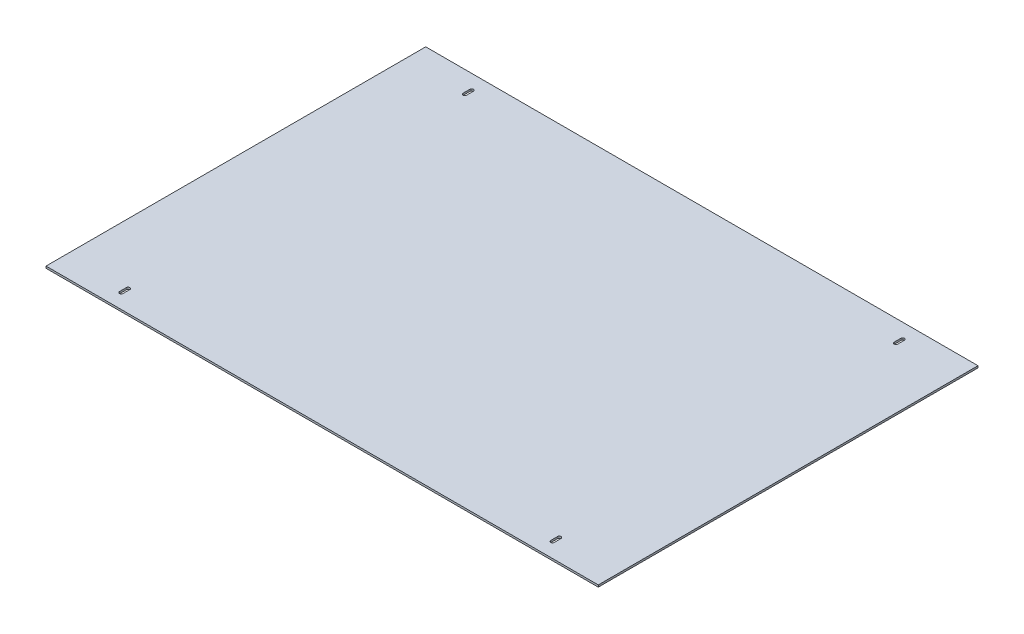
from build123d import *

# Parameters (mm, degrees)
SKETCH1_W           = 715.772
SKETCH1_H           = 492.125
BOSS_EXTRUDE1_DEPTH = 2.54
CUT_EXTRUDE2_DEPTH  = 3.54


with BuildPart() as part:
    # Sketch1 → Boss-Extrude1 (new body)
    with BuildSketch(Plane(origin=(0, 0, 0), x_dir=(1, 0, 0), z_dir=(0, 1, 0))):
        Rectangle(SKETCH1_W, SKETCH1_H)
    extrude(amount=BOSS_EXTRUDE1_DEPTH)

    # Sketch6 → Cut-Extrude2 (cut, through all)
    with BuildSketch(Plane(origin=(0, 2.54, 0), x_dir=(1, 0, 0), z_dir=(0, 1, 0))):
        with BuildLine():
            Line((277.1521, 218.1225), (277.1521, 227.0125))
            ThreePointArc((277.1521, 227.0125), (279.4, 229.2604), (281.6479, 227.0125))
            Line((281.6479, 227.0125), (281.6479, 218.1225))
            ThreePointArc((281.6479, 218.1225), (279.4, 215.8746), (277.1521, 218.1225))
        make_face()
        with BuildLine():
            Line((-277.1521, 218.1225), (-277.1521, 227.0125))
            ThreePointArc((-277.1521, 227.0125), (-279.4, 229.2604), (-281.6479, 227.0125))
            Line((-281.6479, 227.0125), (-281.6479, 218.1225))
            ThreePointArc((-281.6479, 218.1225), (-279.4, 215.8746), (-277.1521, 218.1225))
        make_face()
        with BuildLine():
            Line((277.1521, -218.1225), (277.1521, -227.0125))
            ThreePointArc((277.1521, -227.0125), (279.4, -229.2604), (281.6479, -227.0125))
            Line((281.6479, -227.0125), (281.6479, -218.1225))
            ThreePointArc((281.6479, -218.1225), (279.4, -215.8746), (277.1521, -218.1225))
        make_face()
        with BuildLine():
            Line((-277.1521, -218.1225), (-277.1521, -227.0125))
            ThreePointArc((-277.1521, -227.0125), (-279.4, -229.2604), (-281.6479, -227.0125))
            Line((-281.6479, -227.0125), (-281.6479, -218.1225))
            ThreePointArc((-281.6479, -218.1225), (-279.4, -215.8746), (-277.1521, -218.1225))
        make_face()
    extrude(amount=-CUT_EXTRUDE2_DEPTH, mode=Mode.SUBTRACT)


solid = part.part
